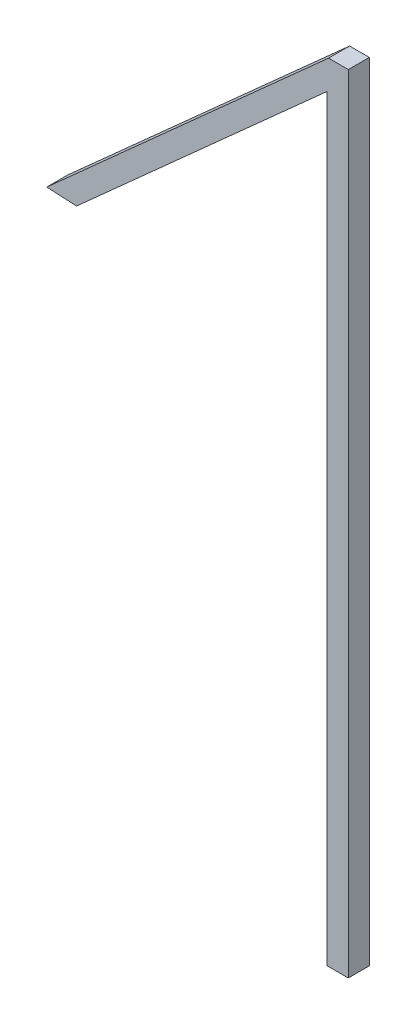
from build123d import *

# Parameters (mm, degrees)
BOSS_EXTRUDE1_DEPTH = 0.5


with BuildPart() as part:
    # Sketch1 → Boss-Extrude1 (new body)
    with BuildSketch(Plane.XY):
        Polygon((0.710413852, 19.361506563), (6.668230523, 24.700459691), (6.668230523, 6.700459691), (7.168230523, 6.700459691), (7.168230523, 25.399996791), (6.699643759, 25.399996791), (0, 19.396273283), align=None)
    extrude(amount=BOSS_EXTRUDE1_DEPTH)


solid = part.part
